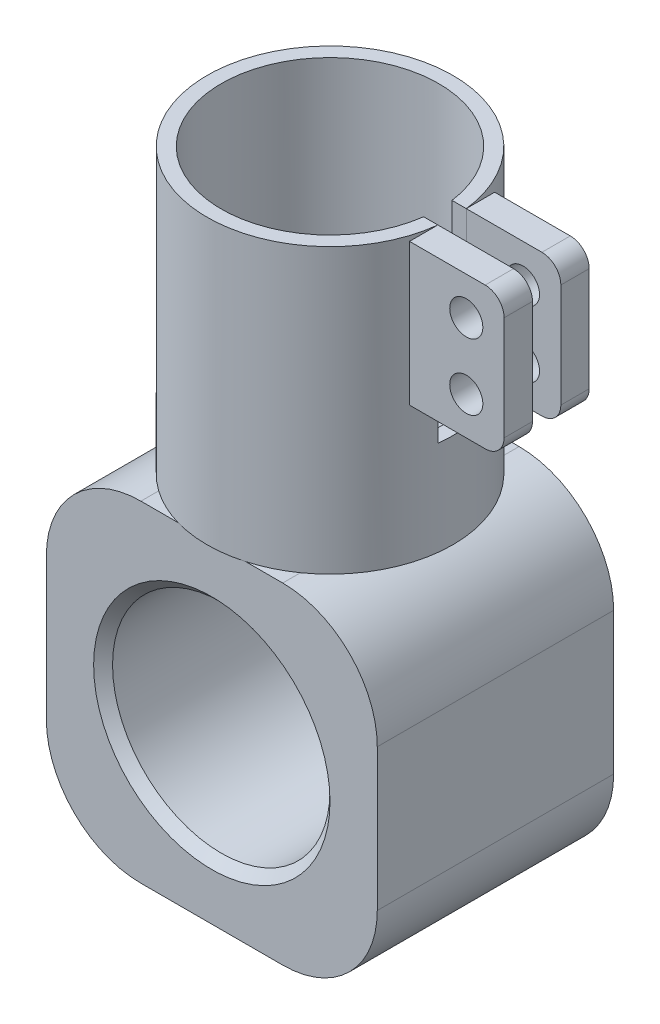
from build123d import *

# Parameters (mm, degrees)
SKETCH1_R           = 11.5
BOSS_EXTRUDE2_DEPTH = 12.5
SKETCH4_R           = 13
SKETCH4_R_2         = 11.5
BOSS_EXTRUDE3_DEPTH = 30
SKETCH5_W           = 11.805491749
SKETCH5_H           = 20
CUT_EXTRUDE1_DEPTH  = 1.5
SKETCH7_R           = 1.75
BOSS_EXTRUDE4_DEPTH = 3
SKETCH8_R           = 1.75
BOSS_EXTRUDE6_DEPTH = 3
CHAMFER1_SIZE       = 1


with BuildPart() as part:
    # Sketch1 → Boss-Extrude2 (new body, symmetric)
    with BuildSketch(Plane.XY):
        with BuildLine():
            Line((-7.5, 17.5), (7.5, 17.5))
            ThreePointArc((7.5, 17.5), (14.571067812, 14.571067812), (17.5, 7.5))
            Line((17.5, 7.5), (17.5, -7.5))
            ThreePointArc((17.5, -7.5), (14.571067812, -14.571067812), (7.5, -17.5))
            Line((7.5, -17.5), (-7.5, -17.5))
            ThreePointArc((-7.5, -17.5), (-14.571067812, -14.571067812), (-17.5, -7.5))
            Line((-17.5, -7.5), (-17.5, 7.5))
            ThreePointArc((-17.5, 7.5), (-14.571067812, 14.571067812), (-7.5, 17.5))
        make_face()
        Circle(SKETCH1_R, mode=Mode.SUBTRACT)
    extrude(amount=BOSS_EXTRUDE2_DEPTH, both=True)

    # Sketch4 → Boss-Extrude3 (add)
    with BuildSketch(Plane(origin=(0, 17.5, 0), x_dir=(1, 0, 0), z_dir=(0, 1, 0))):
        Circle(SKETCH4_R)
        Circle(SKETCH4_R_2, mode=Mode.SUBTRACT)
    extrude(amount=BOSS_EXTRUDE3_DEPTH)

    # Sketch5 → Cut-Extrude1 (cut, symmetric)
    with BuildSketch(Plane.XY):
        with Locations((11.85964538, 37.5)):
            Rectangle(SKETCH5_W, SKETCH5_H)
    extrude(amount=CUT_EXTRUDE1_DEPTH, both=True, mode=Mode.SUBTRACT)

    # Chamfer1
    chamfer1_edges = [part.edges().sort_by_distance(p)[0] for p in [
        (-11.5, 0, -12.5),
        (-11.5, 0, 12.5),
    ]]
    chamfer(chamfer1_edges, length=CHAMFER1_SIZE)


with BuildPart() as body_2:
    # Sketch7 → Boss-Extrude4 (new body)
    with BuildSketch(Plane(origin=(0, 0, 1.5), x_dir=(-1, 0, 0), z_dir=(0, 0, -1))):
        with BuildLine():
            Line((-12.91317157, 47.5), (-20.91317157, 47.5))
            ThreePointArc((-20.91317157, 47.5), (-22.327385133, 46.914213562), (-22.91317157, 45.5))
            Line((-22.91317157, 45.5), (-22.91317157, 34.5))
            ThreePointArc((-22.91317157, 34.5), (-22.327385133, 33.085786438), (-20.91317157, 32.5))
            Line((-20.91317157, 32.5), (-12.91317157, 32.5))
            Line((-12.91317157, 32.5), (-12.91317157, 47.5))
        make_face()
        with Locations((-18.91317157, 43.5)):
            Circle(SKETCH7_R, mode=Mode.SUBTRACT)
        with Locations((-18.91317157, 36.5)):
            Circle(SKETCH7_R, mode=Mode.SUBTRACT)
    extrude(amount=-BOSS_EXTRUDE4_DEPTH)


with BuildPart() as body_3:
    # Sketch8 → Boss-Extrude6 (new body)
    with BuildSketch(Plane.XY.offset(-1.5)):
        with BuildLine():
            Line((12.91317157, 47.5), (12.91317157, 32.5))
            Line((12.91317157, 32.5), (20.91317157, 32.5))
            ThreePointArc((20.91317157, 32.5), (22.327385133, 33.085786438), (22.91317157, 34.5))
            Line((22.91317157, 34.5), (22.91317157, 45.5))
            ThreePointArc((22.91317157, 45.5), (22.327385133, 46.914213562), (20.91317157, 47.5))
            Line((20.91317157, 47.5), (12.91317157, 47.5))
        make_face()
        with Locations((18.91317157, 36.5)):
            Circle(SKETCH8_R, mode=Mode.SUBTRACT)
        with Locations((18.91317157, 43.5)):
            Circle(SKETCH8_R, mode=Mode.SUBTRACT)
    extrude(amount=-BOSS_EXTRUDE6_DEPTH)


solid = Compound([part.part, body_2.part, body_3.part])
